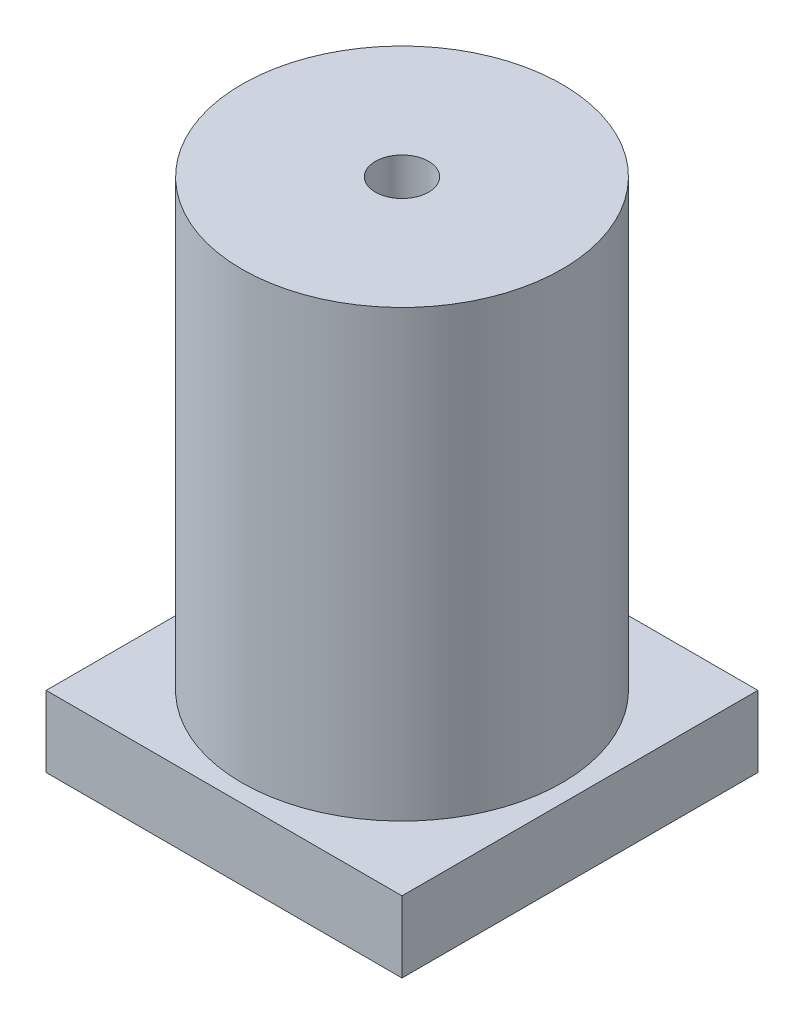
from build123d import *

# Parameters (mm, degrees)
ESBO_O2_W                = 200
ESBO_O2_H                = 200
RESSALTO_EXTRUS_O1_DEPTH = 40
ESBO_O3_R                = 90
RESSALTO_EXTRUS_O2_DEPTH = 250
ESBO_O4_R                = 15
CORTE_EXTRUS_O1_DEPTH    = 25


with BuildPart() as part:
    # Esboço2 → Ressalto-extrusão1 (new body)
    with BuildSketch(Plane(origin=(0, 0, 0), x_dir=(1, 0, 0), z_dir=(0, 1, 0))):
        Rectangle(ESBO_O2_W, ESBO_O2_H)
    extrude(amount=RESSALTO_EXTRUS_O1_DEPTH)

    # Esboço3 → Ressalto-extrusão2 (add)
    with BuildSketch(Plane(origin=(0, 40, 0), x_dir=(1, 0, 0), z_dir=(0, 1, 0))):
        Circle(ESBO_O3_R)
    extrude(amount=RESSALTO_EXTRUS_O2_DEPTH)

    # Esboço4 → Corte-extrusão1 (cut)
    with BuildSketch(Plane(origin=(0, 290, 0), x_dir=(1, 0, 0), z_dir=(0, 1, 0))):
        Circle(ESBO_O4_R)
    extrude(amount=-CORTE_EXTRUS_O1_DEPTH, mode=Mode.SUBTRACT)


solid = part.part
